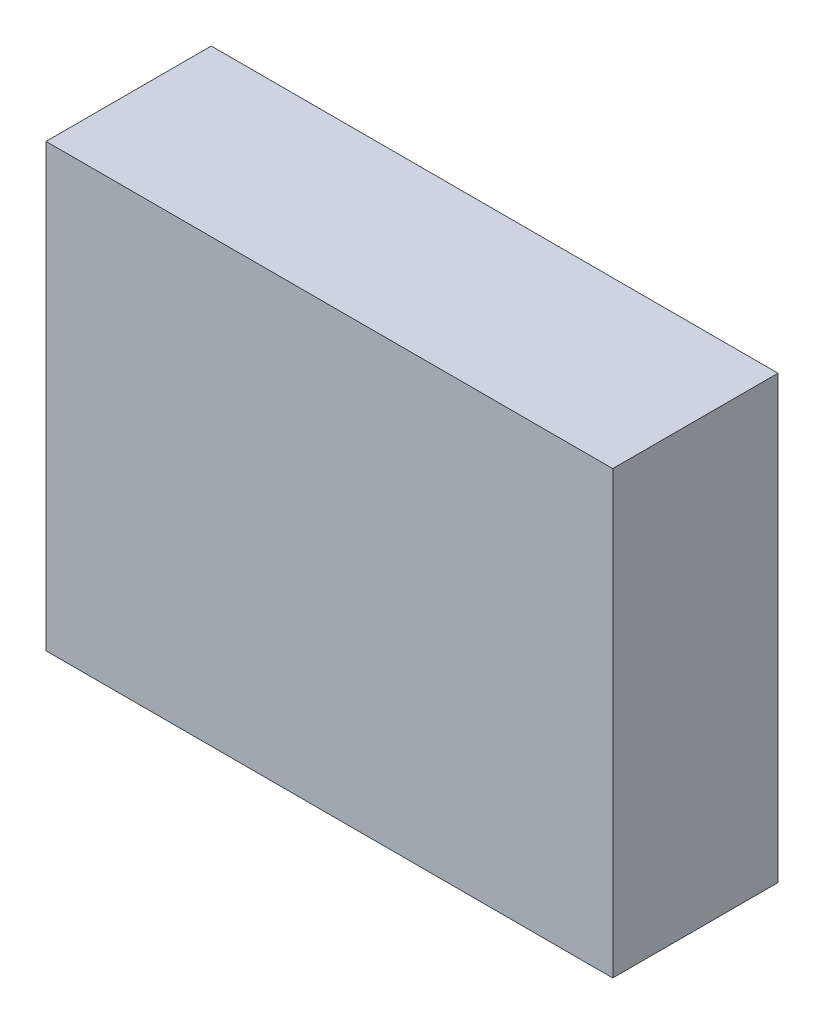
from build123d import *

# Parameters (mm, degrees)
SKETCH1_W           = 68.6
SKETCH1_H           = 53.4
BOSS_EXTRUDE1_DEPTH = 20


with BuildPart() as part:
    # Sketch1 → Boss-Extrude1 (new body)
    with BuildSketch(Plane.XY):
        Rectangle(SKETCH1_W, SKETCH1_H)
    extrude(amount=BOSS_EXTRUDE1_DEPTH)


solid = part.part
